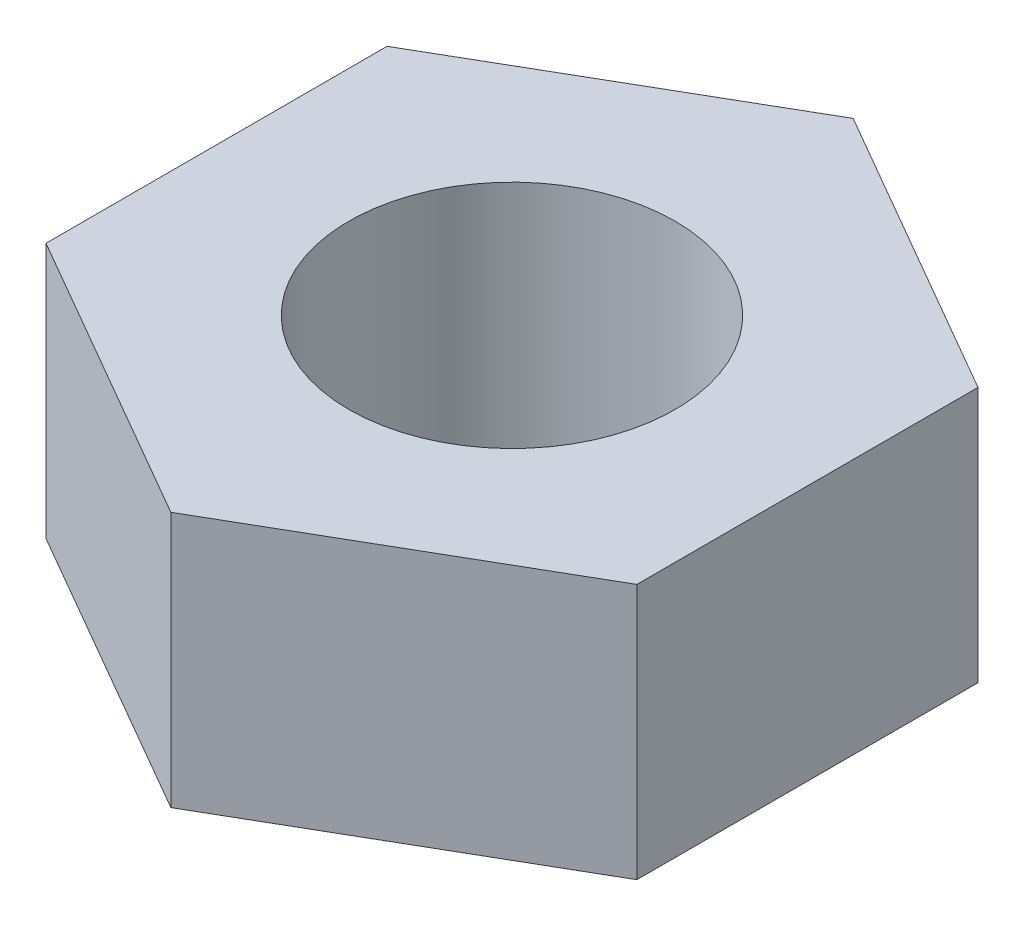
from build123d import *

# Parameters (mm, degrees)
BOSS_EXTRUDE1_DEPTH = 2.9
CUT_EXTRUDE1_REACH  = 4.9
SKETCH2_R           = 1.85


with BuildPart() as part:
    # Sketch1 → Boss-Extrude1 (new body)
    with BuildSketch(Plane(origin=(0, 0, 0), x_dir=(1, 0, 0), z_dir=(0, 1, 0))):
        Polygon((0, 3.868246804), (-3.35, 1.934123402), (-3.35, -1.934123402), (0, -3.868246804), (3.35, -1.934123402), (3.35, 1.934123402), align=None)
    extrude(amount=BOSS_EXTRUDE1_DEPTH)

    # Sketch2 → Cut-Extrude1 (cut, up to next)
    with BuildSketch(Plane(origin=(0, 2.9, 0), x_dir=(1, 0, 0), z_dir=(0, 1, 0)), mode=Mode.PRIVATE) as cut_extrude1_sk1:
        Circle(SKETCH2_R)
    cut_extrude1_tool1 = extrude(cut_extrude1_sk1.sketch, amount=-CUT_EXTRUDE1_REACH, mode=Mode.PRIVATE) & part.part
    add(cut_extrude1_tool1.solids().sort_by_distance((0, 2.9, 0))[0], mode=Mode.SUBTRACT)


solid = part.part
